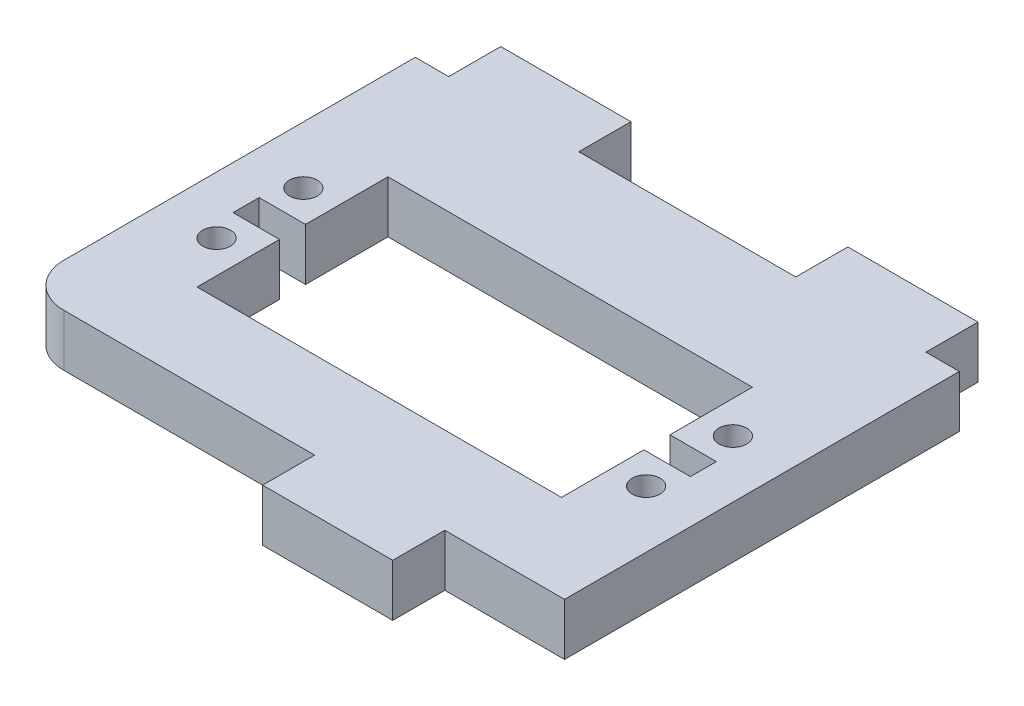
from build123d import *

# Parameters (mm, degrees)
ESBO_O1_R                = 1.6
RESSALTO_EXTRUS_O1_DEPTH = 6


with BuildPart() as part:
    # Esboço1 → Ressalto-extrusão1 (new body)
    with BuildSketch(Plane.XZ.offset(6)):
        with BuildLine():
            Line((2.55259, 21), (-26.35, 21))
            ThreePointArc((-26.35, 21), (-29.885533906, 19.535533906), (-31.35, 16))
            Line((-31.35, 16), (-31.35, -24.5))
            Line((-31.35, -24.5), (-27.5, -24.5))
            Line((-27.5, -24.5), (-27.5, -30.5))
            Line((-27.5, -30.5), (-12.5, -30.5))
            Line((-12.5, -30.5), (-12.5, -24.5))
            Line((-12.5, -24.5), (12.5, -24.5))
            Line((12.5, -24.5), (12.5, -30.5))
            Line((12.5, -30.5), (27.5, -30.5))
            Line((27.5, -30.5), (27.5, -24.5))
            Line((27.5, -24.5), (31.35, -24.5))
            Line((31.35, -24.5), (31.35, 21))
            Line((31.35, 21), (17.55259, 21))
            Line((17.55259, 21), (17.55259, 27))
            Line((17.55259, 27), (2.55259, 27))
            Line((2.55259, 27), (2.55259, 21))
        make_face()
        with Locations((24.75, 5)):
            Circle(ESBO_O1_R, mode=Mode.SUBTRACT)
        with Locations((24.75, -5)):
            Circle(ESBO_O1_R, mode=Mode.SUBTRACT)
        with Locations((-24.75, 5)):
            Circle(ESBO_O1_R, mode=Mode.SUBTRACT)
        with Locations((-24.75, -5)):
            Circle(ESBO_O1_R, mode=Mode.SUBTRACT)
        Polygon((-26.35, 1.5), (-21, 1.5), (-21, 11), (21, 11), (21, 1.5), (26.35, 1.5), (26.35, -1.5), (21, -1.5), (21, -11), (-21, -11), (-21, -1.5), (-26.35, -1.5), align=None, mode=Mode.SUBTRACT)
    extrude(amount=-RESSALTO_EXTRUS_O1_DEPTH)


solid = part.part
